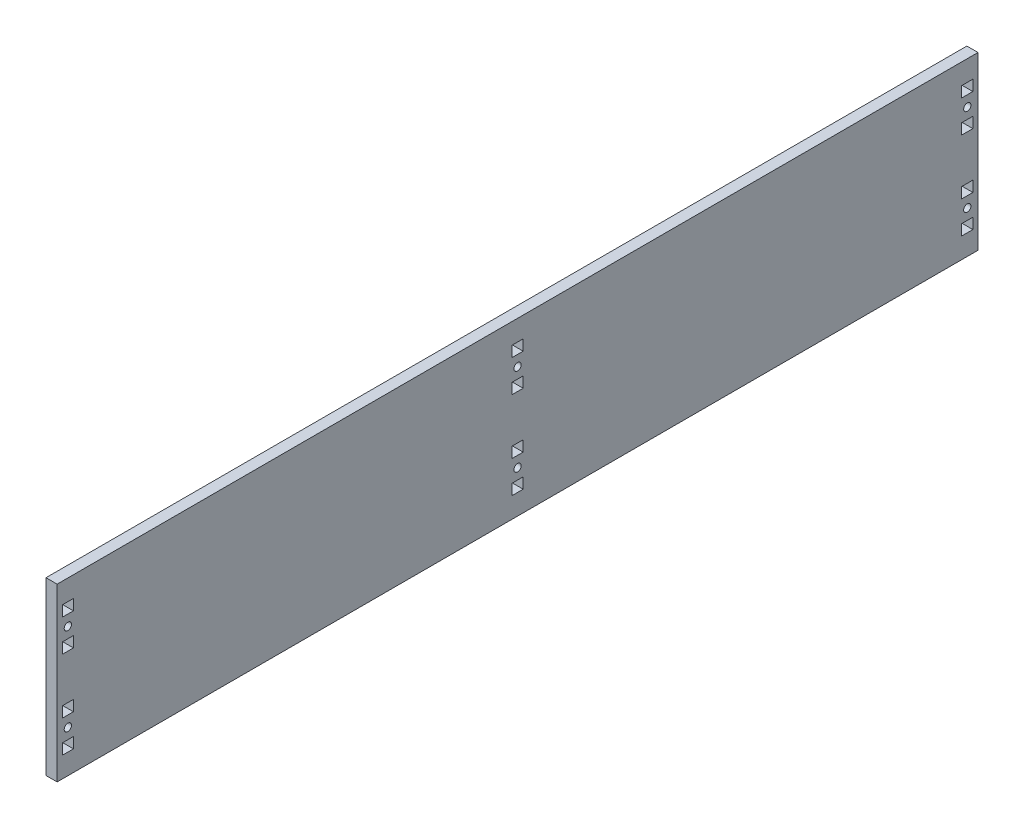
from build123d import *

# Parameters (mm, degrees)
SKETCH1_W                                         = 546.1
SKETCH1_H                                         = 101.6
SKETCH1_R                                         = 2.15265
SKETCH1_W_2                                       = 6.604
SKETCH1_H_2                                       = 6.35
BOSS_EXTRUDE1_DEPTH                               = 6.604
CSK_FOR_8_FLAT_HEAD_SOCKET_CAP_SCREW2_D           = 4.3053
CSK_FOR_8_FLAT_HEAD_SOCKET_CAP_SCREW2_CSINK_D     = 9.1186
CSK_FOR_8_FLAT_HEAD_SOCKET_CAP_SCREW2_CSINK_ANGLE = 82


with BuildPart() as part:
    # Sketch1 → Boss-Extrude1 (new body)
    with BuildSketch(Plane(origin=(0, 0, 0), x_dir=(0, 0, -1), z_dir=(1, 0, 0))):
        Rectangle(SKETCH1_W, SKETCH1_H)
        with Locations((-266.7, 25.9207)):
            Circle(SKETCH1_R, mode=Mode.SUBTRACT)
        with Locations((-266.7, -25.9207)):
            Circle(SKETCH1_R, mode=Mode.SUBTRACT)
        with Locations((0, -25.9207)):
            Circle(SKETCH1_R, mode=Mode.SUBTRACT)
        with Locations((0, 25.9207)):
            Circle(SKETCH1_R, mode=Mode.SUBTRACT)
        with Locations((266.7, -25.9207)):
            Circle(SKETCH1_R, mode=Mode.SUBTRACT)
        with Locations((266.7, 25.9207)):
            Circle(SKETCH1_R, mode=Mode.SUBTRACT)
        with Locations((-266.7, 16.3957)):
            Rectangle(SKETCH1_W_2, SKETCH1_H_2, mode=Mode.SUBTRACT)
        with Locations((-266.7, 35.4457)):
            Rectangle(SKETCH1_W_2, SKETCH1_H_2, mode=Mode.SUBTRACT)
        with Locations((-266.7, -35.4457)):
            Rectangle(SKETCH1_W_2, SKETCH1_H_2, mode=Mode.SUBTRACT)
        with Locations((-266.7, -16.3957)):
            Rectangle(SKETCH1_W_2, SKETCH1_H_2, mode=Mode.SUBTRACT)
        with Locations((0, -16.3957)):
            Rectangle(SKETCH1_W_2, SKETCH1_H_2, mode=Mode.SUBTRACT)
        with Locations((0, -35.4457)):
            Rectangle(SKETCH1_W_2, SKETCH1_H_2, mode=Mode.SUBTRACT)
        with Locations((0, 35.4457)):
            Rectangle(SKETCH1_W_2, SKETCH1_H_2, mode=Mode.SUBTRACT)
        with Locations((0, 16.3957)):
            Rectangle(SKETCH1_W_2, SKETCH1_H_2, mode=Mode.SUBTRACT)
        with Locations((266.7, -16.3957)):
            Rectangle(SKETCH1_W_2, SKETCH1_H_2, mode=Mode.SUBTRACT)
        with Locations((266.7, -35.4457)):
            Rectangle(SKETCH1_W_2, SKETCH1_H_2, mode=Mode.SUBTRACT)
        with Locations((266.7, 35.4457)):
            Rectangle(SKETCH1_W_2, SKETCH1_H_2, mode=Mode.SUBTRACT)
        with Locations((266.7, 16.3957)):
            Rectangle(SKETCH1_W_2, SKETCH1_H_2, mode=Mode.SUBTRACT)
    extrude(amount=BOSS_EXTRUDE1_DEPTH)

    # CSK for #8 Flat Head Socket Cap Screw2 (through all)
    with Locations(Plane.ZY):
        with Locations((-266.7, 25.9207), (-266.7, -25.9207), (266.7, -25.9207), (266.7, 25.9207), (0, 25.9207), (0, -25.9207)):
            CounterSinkHole(CSK_FOR_8_FLAT_HEAD_SOCKET_CAP_SCREW2_D / 2, CSK_FOR_8_FLAT_HEAD_SOCKET_CAP_SCREW2_CSINK_D / 2, counter_sink_angle=CSK_FOR_8_FLAT_HEAD_SOCKET_CAP_SCREW2_CSINK_ANGLE)


solid = part.part
